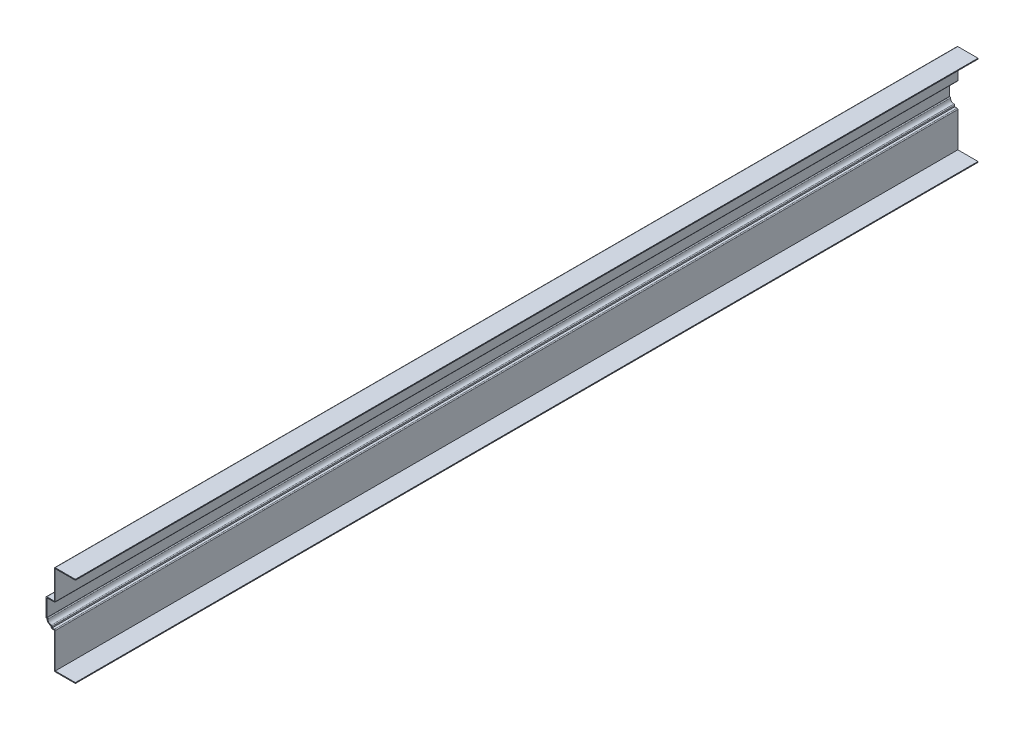
from build123d import *

# Parameters (mm, degrees)
EXTRUDE_THIN1_DEPTH = 1365.25
FILLET1_R           = 1.27


with BuildPart() as part:
    # Sketch1 → Extrude-Thin1 (new body)
    with BuildSketch(Plane.XY):
        with BuildLine():
            Line((0, 0), (-31.75, 0))
            Line((-31.75, 0), (-31.75, 53.975))
            Line((-31.75, 53.975), (-36.5125, 53.975))
            Line((-36.5125, 53.975), (-36.5125, 57.15))
            ThreePointArc((-36.5125, 57.15), (-41.002628061, 59.009871939), (-42.8625, 63.5))
            Line((-42.8625, 63.5), (-44.45, 63.5))
            Line((-44.45, 63.5), (-44.45, 92.075))
            Line((-44.45, 92.075), (-31.75, 92.075))
            Line((-31.75, 92.075), (-31.75, 136.525))
            Line((-31.75, 136.525), (0, 136.525))
            Line((0, 136.525), (0, 135.255))
            Line((0, 135.255), (-30.48, 135.255))
            Line((-30.48, 135.255), (-30.48, 90.805))
            Line((-30.48, 90.805), (-43.18, 90.805))
            Line((-43.18, 90.805), (-43.18, 64.77))
            Line((-43.18, 64.77), (-41.43118885, 64.77))
            ThreePointArc((-41.43118885, 64.77), (-40.104602448, 59.907897552), (-35.2425, 58.58131115))
            Line((-35.2425, 58.58131115), (-35.2425, 55.245))
            Line((-35.2425, 55.245), (-30.48, 55.245))
            Line((-30.48, 55.245), (-30.48, 1.27))
            Line((-30.48, 1.27), (0, 1.27))
            Line((0, 1.27), (0, 0))
        make_face()
    extrude(amount=-EXTRUDE_THIN1_DEPTH)

    # Fillet1
    fillet1_edges = [part.edges().sort_by_distance(p)[0] for p in [
        (-30.48, 90.805, -682.625),
        (-41.43118885, 64.77, -682.625),
        (-35.2425, 58.58131115, -682.625),
        (-30.48, 55.245, -682.625),
        (-31.75, 0, -682.625),
        (-36.5125, 53.975, -682.625),
        (-44.45, 63.5, -682.625),
        (-44.45, 92.075, -682.625),
        (-31.75, 136.525, -682.625),
    ]]
    fillet(fillet1_edges, radius=FILLET1_R)


solid = part.part
